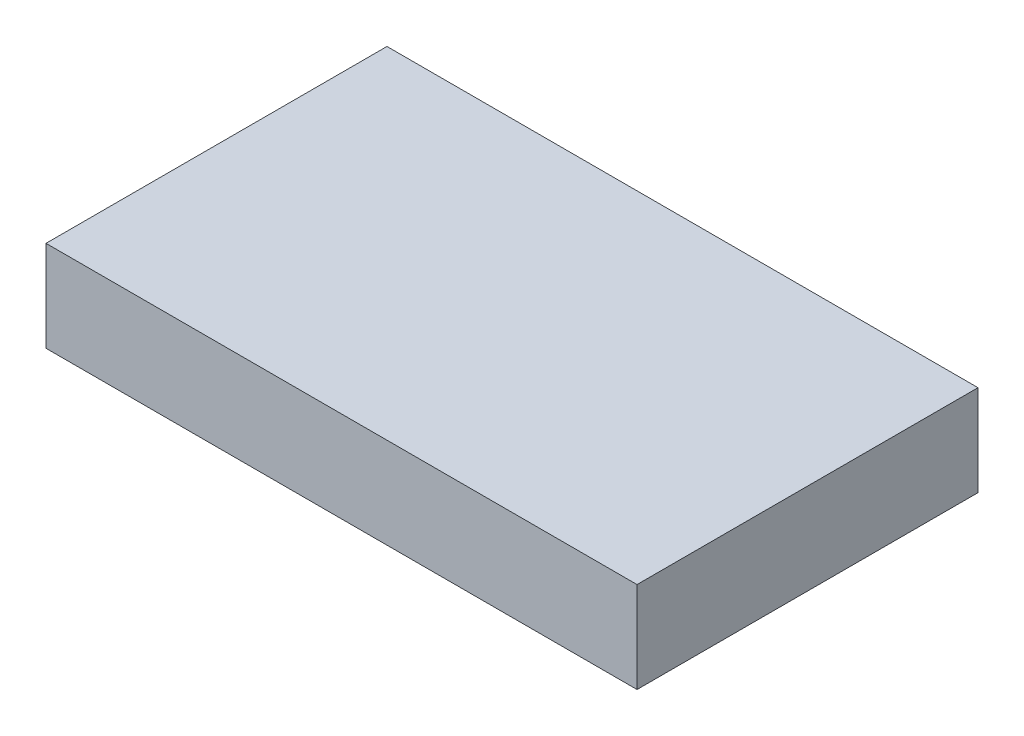
from build123d import *

# Parameters (mm, degrees)
SKETCH1_W           = 52
SKETCH1_H           = 30
BOSS_EXTRUDE1_DEPTH = 8


with BuildPart() as part:
    # Sketch1 → Boss-Extrude1 (new body)
    with BuildSketch(Plane(origin=(0, 0, 0), x_dir=(1, 0, 0), z_dir=(0, 1, 0))):
        with Locations((-1.549033097, 4.812660789)):
            Rectangle(SKETCH1_W, SKETCH1_H)
    extrude(amount=BOSS_EXTRUDE1_DEPTH)


solid = part.part
